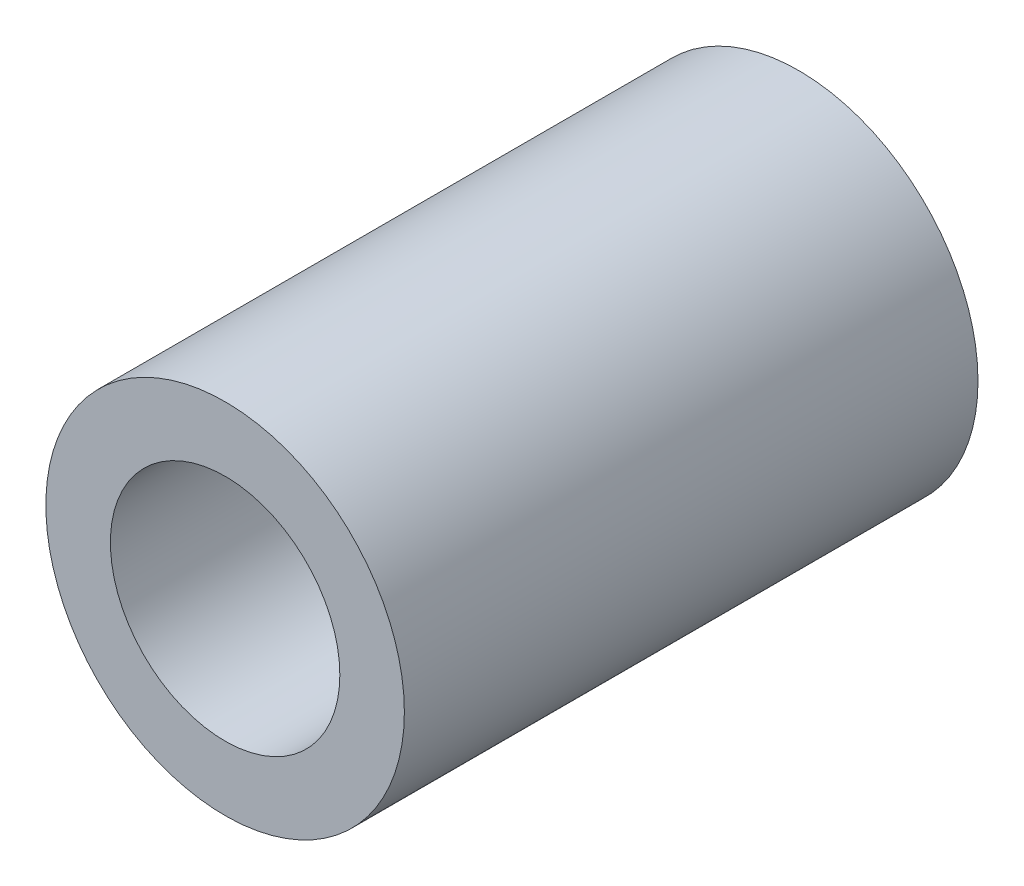
from build123d import *

# Parameters (mm, degrees)
SKETCH_1_R      = 2.5
SKETCH_1_R_2    = 1.6
EXTRUDE_1_DEPTH = 8


with BuildPart() as part:
    # 草图1 → 凸台-拉伸1 (new body)
    with BuildSketch(Plane.XY):
        Circle(SKETCH_1_R)
        Circle(SKETCH_1_R_2, mode=Mode.SUBTRACT)
    extrude(amount=EXTRUDE_1_DEPTH)


solid = part.part
